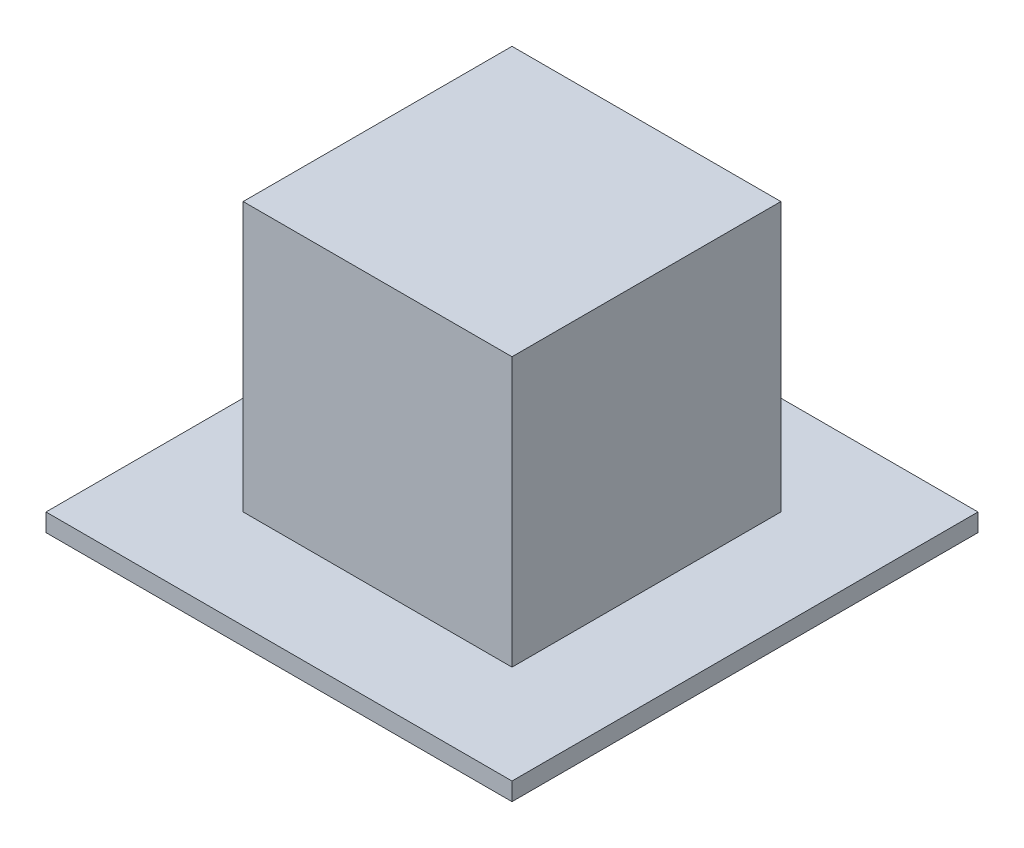
from build123d import *

# Parameters (mm, degrees)
SKETCH1_W           = 15
SKETCH1_H           = 15
BOSS_EXTRUDE1_DEPTH = 15
SKETCH2_W           = 26
SKETCH2_H           = 26
BOSS_EXTRUDE2_DEPTH = 1


with BuildPart() as part:
    # Sketch1 → Boss-Extrude1 (new body)
    with BuildSketch(Plane(origin=(0, 0, 0), x_dir=(1, 0, 0), z_dir=(0, 1, 0))):
        Rectangle(SKETCH1_W, SKETCH1_H)
    extrude(amount=BOSS_EXTRUDE1_DEPTH)

    # Sketch2 → Boss-Extrude2 (add)
    with BuildSketch(Plane.XZ):
        Rectangle(SKETCH2_W, SKETCH2_H)
    extrude(amount=BOSS_EXTRUDE2_DEPTH)


solid = part.part
